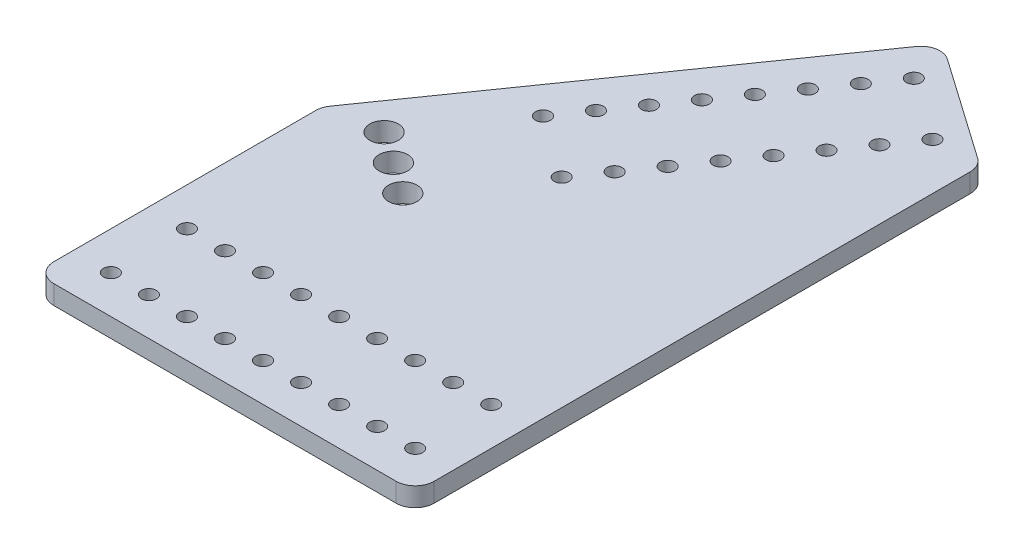
from build123d import *

# Parameters (mm, degrees)
BOSS_EXTRUDE1_DEPTH = 6.35
SKETCH2_R           = 2.4892
SKETCH2_R_2         = 4.7625
CUT_EXTRUDE1_DEPTH  = 7.35
FILLET1_R           = 6.35


with BuildPart() as part:
    # Sketch1 → Boss-Extrude1 (new body)
    with BuildSketch(Plane(origin=(0, 0, 0), x_dir=(1, 0, 0), z_dir=(0, 1, 0))):
        Polygon((0, 95.812682967), (85.38707615, 217.758065572), (127, 188.620382605), (127, 0), (0, 0), align=None)
    extrude(amount=BOSS_EXTRUDE1_DEPTH)

    # Sketch2 → Cut-Extrude1 (cut, through all)
    with BuildSketch(Plane(origin=(0, 6.35, 0), x_dir=(1, 0, 0), z_dir=(0, 1, 0))):
        with Locations((12.7, 12.7)):
            Circle(SKETCH2_R)
        with Locations((12.7, 38.1)):
            Circle(SKETCH2_R)
        with Locations((25.4, 38.1)):
            Circle(SKETCH2_R)
        with Locations((38.1, 38.1)):
            Circle(SKETCH2_R)
        with Locations((50.8, 38.1)):
            Circle(SKETCH2_R)
        with Locations((63.5, 38.1)):
            Circle(SKETCH2_R)
        with Locations((25.4, 12.7)):
            Circle(SKETCH2_R)
        with Locations((38.1, 12.7)):
            Circle(SKETCH2_R)
        with Locations((50.8, 12.7)):
            Circle(SKETCH2_R)
        with Locations((63.5, 12.7)):
            Circle(SKETCH2_R)
        with Locations((76.2, 12.7)):
            Circle(SKETCH2_R)
        with Locations((76.2, 38.1)):
            Circle(SKETCH2_R)
        with Locations((88.9, 12.7)):
            Circle(SKETCH2_R)
        with Locations((88.9, 38.1)):
            Circle(SKETCH2_R)
        with Locations((101.6, 12.7)):
            Circle(SKETCH2_R)
        with Locations((101.6, 38.1)):
            Circle(SKETCH2_R)
        with Locations((90.531859121, 202.963802812)):
            Circle(SKETCH2_R)
        with Locations((111.338321046, 188.394961329)):
            Circle(SKETCH2_R)
        with Locations((83.247438379, 192.56057185)):
            Circle(SKETCH2_R)
        with Locations((104.053900304, 177.991730366)):
            Circle(SKETCH2_R)
        with Locations((75.963017637, 182.157340887)):
            Circle(SKETCH2_R)
        with Locations((96.769479562, 167.588499404)):
            Circle(SKETCH2_R)
        with Locations((68.678596896, 171.754109925)):
            Circle(SKETCH2_R)
        with Locations((89.485058821, 157.185268441)):
            Circle(SKETCH2_R)
        with Locations((61.394176154, 161.350878962)):
            Circle(SKETCH2_R)
        with Locations((82.200638079, 146.782037479)):
            Circle(SKETCH2_R)
        with Locations((54.109755412, 150.947648)):
            Circle(SKETCH2_R)
        with Locations((74.916217337, 136.378806516)):
            Circle(SKETCH2_R)
        with Locations((46.825334671, 140.544417037)):
            Circle(SKETCH2_R)
        with Locations((67.631796596, 125.975575554)):
            Circle(SKETCH2_R)
        with Locations((39.540913929, 130.141186075)):
            Circle(SKETCH2_R)
        with Locations((60.347375854, 115.572344592)):
            Circle(SKETCH2_R)
        with Locations((17.687651704, 98.931493187)):
            Circle(SKETCH2_R_2)
        with Locations((28.090882667, 91.647072446)):
            Circle(SKETCH2_R_2)
        with Locations((38.494113629, 84.362651704)):
            Circle(SKETCH2_R_2)
        with Locations((114.3, 12.7)):
            Circle(SKETCH2_R)
        with Locations((114.3, 38.1)):
            Circle(SKETCH2_R)
    extrude(amount=-CUT_EXTRUDE1_DEPTH, mode=Mode.SUBTRACT)

    # Fillet1
    fillet1_edges = [part.edges().sort_by_distance(p)[0] for p in [
        (0, 3.175, -95.812682967),
        (85.38707615, 3.175, -217.758065572),
        (127, 3.175, -188.620382605),
        (127, 3.175, 0),
        (0, 3.175, 0),
    ]]
    fillet(fillet1_edges, radius=FILLET1_R)


solid = part.part
